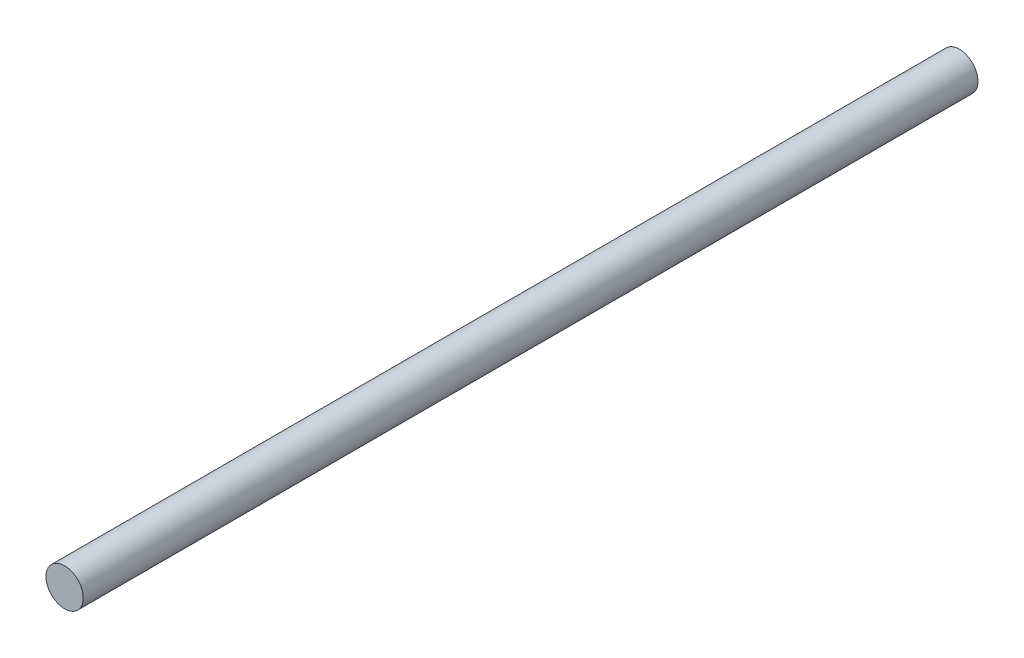
from build123d import *

# Parameters (mm, degrees)
SKETCH1_R           = 1.5875
BOSS_EXTRUDE1_DEPTH = 76.2


with BuildPart() as part:
    # Sketch1 → Boss-Extrude1 (new body)
    with BuildSketch(Plane.XY):
        Circle(SKETCH1_R)
    extrude(amount=BOSS_EXTRUDE1_DEPTH)


solid = part.part
